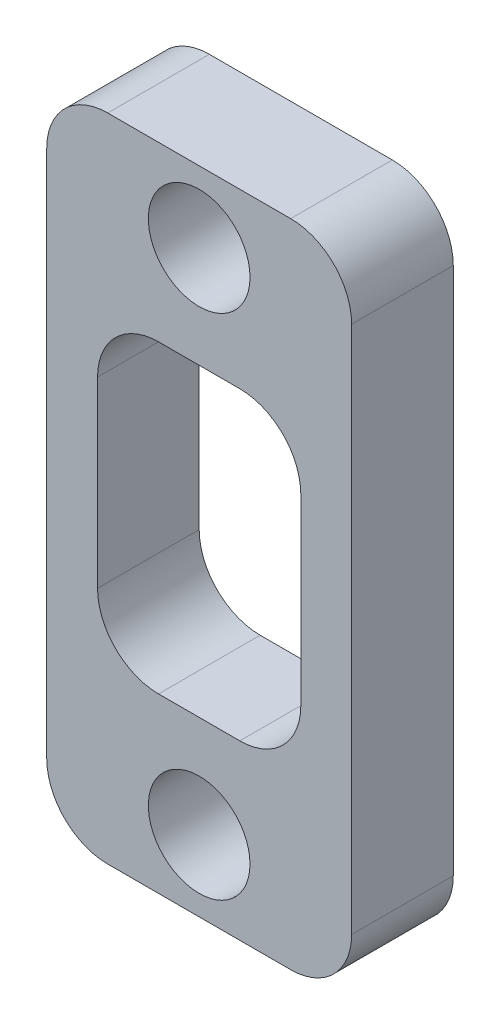
from build123d import *

# Parameters (mm, degrees)
SKETCH_1_W      = 15
SKETCH_1_H      = 32
SKETCH_1_R      = 2.5
SKETCH_1_W_2    = 10
SKETCH_1_H_2    = 15
EXTRUDE_1_DEPTH = 5
FILLET_1_R      = 3


with BuildPart() as part:
    # 草图1 → 凸台-拉伸1 (new body)
    with BuildSketch(Plane.XY):
        with Locations((0, 12.5)):
            Rectangle(SKETCH_1_W, SKETCH_1_H)
        with Locations((0, 25)):
            Circle(SKETCH_1_R, mode=Mode.SUBTRACT)
        Circle(SKETCH_1_R, mode=Mode.SUBTRACT)
        with Locations((0, 12.5)):
            Rectangle(SKETCH_1_W_2, SKETCH_1_H_2, mode=Mode.SUBTRACT)
    extrude(amount=EXTRUDE_1_DEPTH)

    # 圆角1
    fillet_1_edges = [part.edges().sort_by_distance(p)[0] for p in [
        (5, 5, 2.5),
        (5, 20, 2.5),
        (-5, 20, 2.5),
        (-5, 5, 2.5),
        (7.5, -3.5, 2.5),
        (-7.5, -3.5, 2.5),
        (-7.5, 28.5, 2.5),
        (7.5, 28.5, 2.5),
    ]]
    fillet(fillet_1_edges, radius=FILLET_1_R)


solid = part.part
